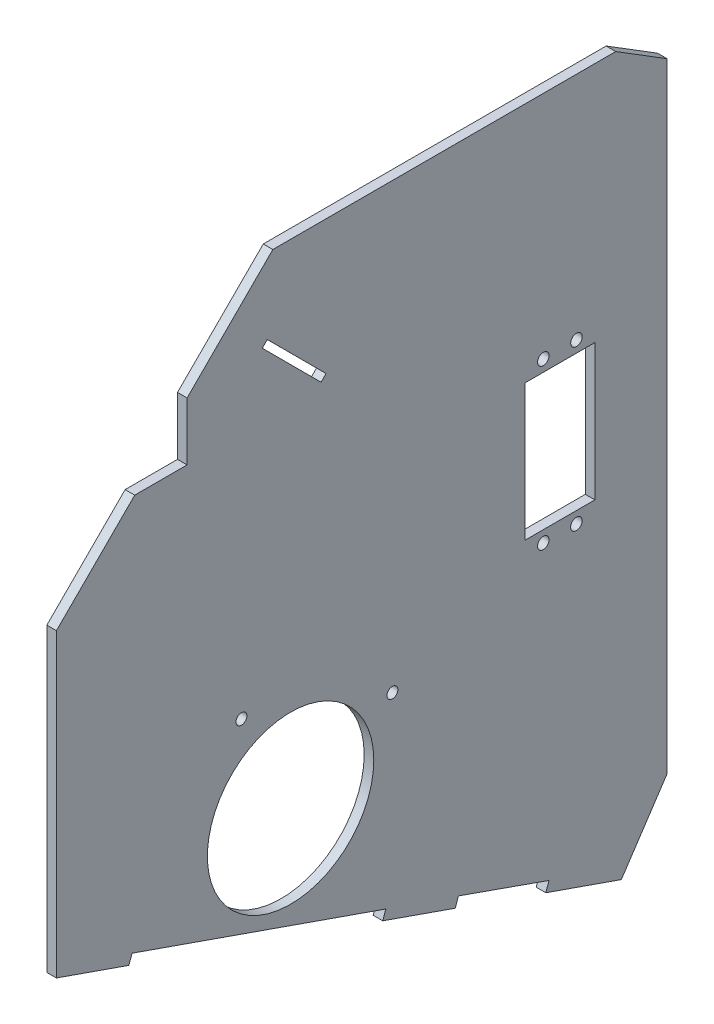
from build123d import *

# Parameters (mm, degrees)
SKETCH1_R           = 1.7
SKETCH1_R_2         = 26
SKETCH1_R_3         = 1.8
SKETCH1_W           = 21.878233713
SKETCH1_H           = 42.578781785
BOSS_EXTRUDE1_DEPTH = 3


with BuildPart() as part:
    # Sketch1 → Boss-Extrude1 (new body)
    with BuildSketch(Plane(origin=(0, 0, 0), x_dir=(0, 0, -1), z_dir=(1, 0, 0))):
        Polygon((-110.882382617, -2.731166398), (-88.223157403, -10.643032479), (-87.23420686, -7.810723029), (-58.937631543, -17.77378609), (-59.926582085, -20.606095541), (-36.324038311, -28.84733785), (-22.003393348, -7.322703446), (-22.003393348, 186.164699152), (-38.083447414, 196.14277913), (-145.230517161, 196.14277913), (-172.036164941, 169.366182911), (-172.036164941, 151.244509979), (-188.398196234, 151.244509979), (-212.871297543, 126.797932251), (-212.871297543, 32.797235558), (-190.212821939, 24.885631216), (-189.235943541, 27.683366592), (-109.931278924, -0.007248606), align=None)
        with Locations((-155.039998164, 73.999598468)):
            Circle(SKETCH1_R, mode=Mode.SUBTRACT)
        with Locations((-107.865704399, 57.52786604)):
            Circle(SKETCH1_R, mode=Mode.SUBTRACT)
        with Locations((-139.694105805, 42.161153499)):
            Circle(SKETCH1_R_2, mode=Mode.SUBTRACT)
        with Locations((-60.718323374, 74.451599653)):
            Circle(SKETCH1_R_3, mode=Mode.SUBTRACT)
        with Locations((-50.368324245, 74.447353909)):
            Circle(SKETCH1_R_3, mode=Mode.SUBTRACT)
        with Locations((-60.697894576, 124.251595463)):
            Circle(SKETCH1_R_3, mode=Mode.SUBTRACT)
        with Locations((-50.347895446, 124.247349719)):
            Circle(SKETCH1_R_3, mode=Mode.SUBTRACT)
        Polygon((-148.535091588, 171.081773838), (-146.971590994, 172.643579934), (-128.596785358, 154.248838352), (-130.160285952, 152.687032257), align=None, mode=Mode.SUBTRACT)
        with Locations((-55.533109411, 99.349474686)):
            Rectangle(SKETCH1_W, SKETCH1_H, mode=Mode.SUBTRACT)
    extrude(amount=BOSS_EXTRUDE1_DEPTH)


solid = part.part
